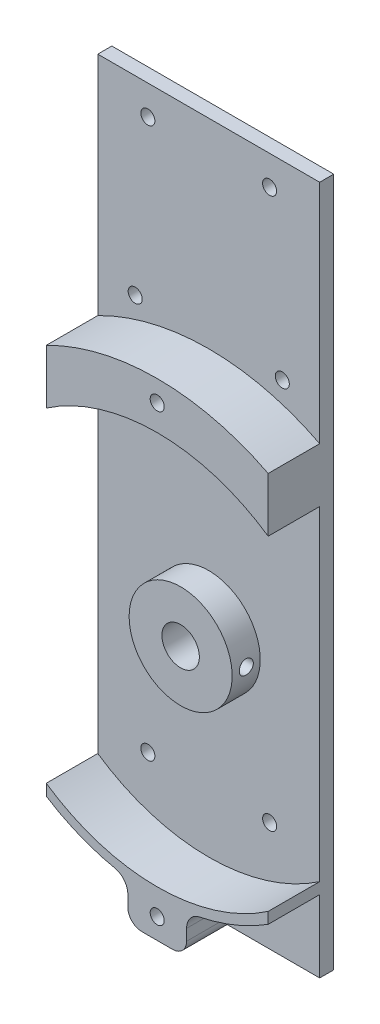
from build123d import *

# Parameters (mm, degrees)
BOSS_EXTRUDE2_DEPTH      = 32.13354
BOSS_EXTRUDE2_DEPTH_BACK = 115
SKETCH1_W                = 47.380920583
SKETCH1_H                = 3
SKETCH3_R                = 1.5
SKETCH3_R_2              = 4
CUT_EXTRUDE1_DEPTH       = 10
SKETCH4_R                = 1.5
BOSS_EXTRUDE6_DEPTH      = 11
CUT_EXTRUDE2_START       = -10
SKETCH4_3_R              = 1.5
CUT_EXTRUDE2_DEPTH       = 10
SKETCH3_5_R              = 11
SKETCH3_5_R_2            = 4
BOSS_EXTRUDE7_DEPTH      = 9
SKETCH8_R                = 1.5
CUT_EXTRUDE3_DEPTH       = 9


with BuildPart() as part:
    # Sketch1 → Boss-Extrude2 (new, two sides: drawn at the far end of the back side and taken through both)
    with BuildSketch(Plane(origin=(0, 0, 0), x_dir=(1, 0, 0), z_dir=(0, 1, 0)).offset(-BOSS_EXTRUDE2_DEPTH_BACK)):
        with Locations((-0.010103172, -96.309011723)):
            Rectangle(SKETCH1_W, SKETCH1_H)
    extrude(amount=BOSS_EXTRUDE2_DEPTH + BOSS_EXTRUDE2_DEPTH_BACK)

    # Sketch3 → Cut-Extrude1 (cut)
    with BuildSketch(Plane(origin=(0, 0, 94.809011723), x_dir=(-1, 0, 0), z_dir=(0, 0, -1))):
        with Locations((-12.989896828, -91.59646)):
            Circle(SKETCH3_R)
        with Locations((0.010103172, -62.5)):
            Circle(SKETCH3_R_2)
        with Locations((13.010103172, -91.59646)):
            Circle(SKETCH3_R)
        with Locations((-15.690228452, -8.417274823)):
            Circle(SKETCH3_R)
        with Locations((15.713451538, -8.447491658)):
            Circle(SKETCH3_R)
        with Locations((13.010103172, 25.86354)):
            Circle(SKETCH3_R)
        with Locations((-12.989896828, 25.86354)):
            Circle(SKETCH3_R)
    extrude(amount=-CUT_EXTRUDE1_DEPTH, mode=Mode.SUBTRACT)

    # Sketch4 → Boss-Extrude6 (add)
    # profile 1 of 2: a face of its own
    with BuildSketch(Plane.XY.offset(97.809011723)):
        with BuildLine():
            ThreePointArc((8.69292522, -105.630700166), (16.466971046, -103.298358119), (23.68035712, -99.577784335))
            Line((23.68035712, -99.577784335), (23.68035712, -97.180860589))
            ThreePointArc((23.68035712, -97.180860589), (-0.010103172, -104.5), (-23.700563463, -97.180860589))
            Line((-23.700563463, -97.180860589), (-23.700563463, -99.577784335))
            ThreePointArc((-23.700563463, -99.577784335), (-16.487177389, -103.298358119), (-8.713131563, -105.630700166))
            ThreePointArc((-8.713131563, -105.630700166), (-6.946765802, -106.93432478), (-6.283436573, -109.027045372))
            Line((-6.283436573, -109.027045372), (-6.283436573, -111.414142146))
            ThreePointArc((-6.283436573, -111.414142146), (-5.602096929, -113.317773977), (-3.867560473, -114.35672592))
            ThreePointArc((-3.867560473, -114.35672592), (-3.432425137, -114.387259634), (-2.997048979, -114.414142146))
            Line((-2.997048979, -114.414142146), (2.976842636, -114.414142146))
            ThreePointArc((2.976842636, -114.414142146), (3.412218794, -114.387259634), (3.84735413, -114.35672592))
            ThreePointArc((3.84735413, -114.35672592), (5.581890586, -113.317773977), (6.263230229, -111.414142146))
            Line((6.263230229, -111.414142146), (6.263230229, -109.027045372))
            ThreePointArc((6.263230229, -109.027045372), (6.926559458, -106.93432478), (8.69292522, -105.630700166))
        make_face()
        with Locations((-0.010103172, -110)):
            Circle(SKETCH4_R, mode=Mode.SUBTRACT)
    # profile 2 of 2: a face of its own
    with BuildSketch(Plane.XY.offset(97.809011723)):
        with BuildLine():
            ThreePointArc((-23.700563463, -27.819139411), (-0.010103172, -20.5), (23.68035712, -27.819139411))
            Line((23.68035712, -27.819139411), (23.68035712, -16.210021698))
            ThreePointArc((23.68035712, -16.210021698), (-0.010103172, -10.5), (-23.700563463, -16.210021698))
            Line((-23.700563463, -16.210021698), (-23.700563463, -27.819139411))
        make_face()
        with Locations((-0.010103172, -15)):
            Circle(SKETCH4_R, mode=Mode.SUBTRACT)
    extrude(amount=BOSS_EXTRUDE6_DEPTH)

    # Sketch4_3 → Cut-Extrude2 (cut)
    with BuildSketch(Plane.XY.offset(97.809011723).offset(CUT_EXTRUDE2_START)):
        with Locations((-0.010103172, -110)):
            Circle(SKETCH4_3_R)
        with Locations((-0.010103172, -15)):
            Circle(SKETCH4_3_R)
    extrude(amount=CUT_EXTRUDE2_DEPTH, mode=Mode.SUBTRACT)

    # Sketch3_5 → Boss-Extrude7 (add)
    with BuildSketch(Plane(origin=(0, 0, 94.809011723), x_dir=(-1, 0, 0), z_dir=(0, 0, -1))):
        with Locations((0.010103172, -62.5)):
            Circle(SKETCH3_5_R)
        with Locations((0.010103172, -62.5)):
            Circle(SKETCH3_5_R_2, mode=Mode.SUBTRACT)
    extrude(amount=-BOSS_EXTRUDE7_DEPTH)

    # Sketch8 → Cut-Extrude3 (cut)
    with BuildSketch(Plane(origin=(10.989896828, 0, 0), x_dir=(0, 0, -1), z_dir=(1, 0, 0))):
        with Locations((-100.78123084, -62.396797047)):
            Circle(SKETCH8_R)
    extrude(amount=-CUT_EXTRUDE3_DEPTH, mode=Mode.SUBTRACT)


solid = part.part
